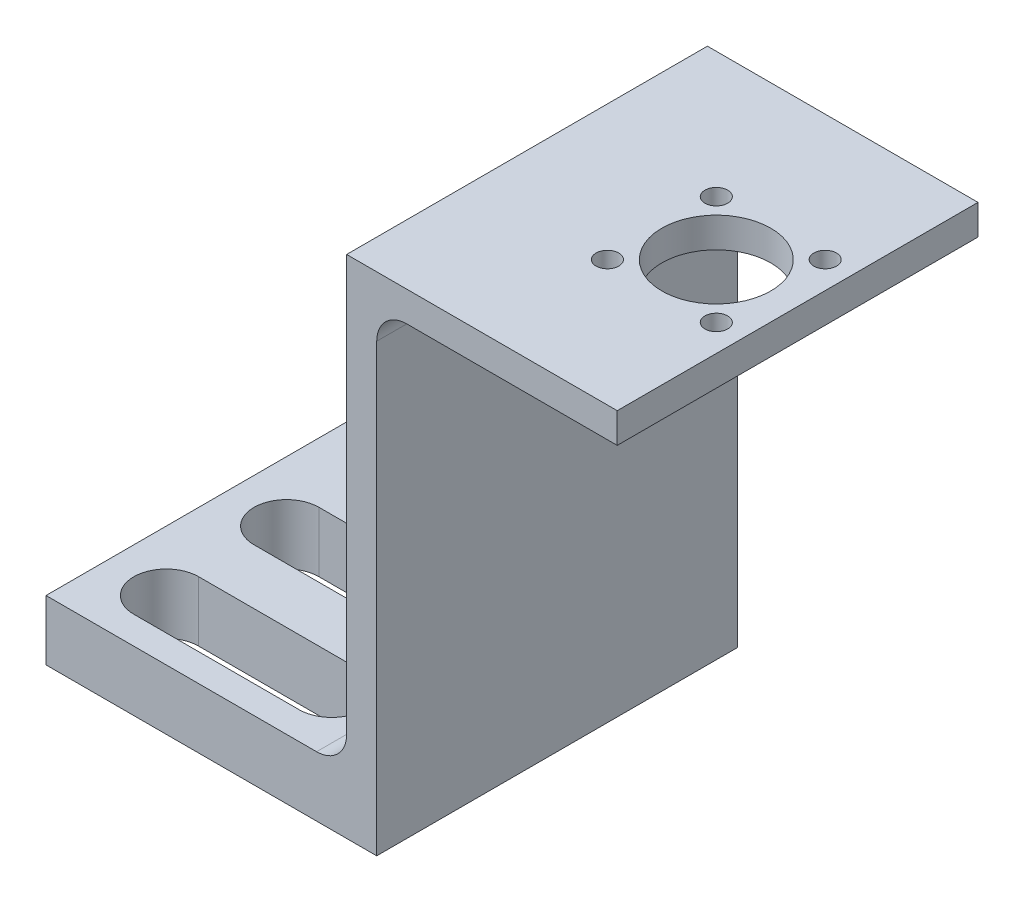
from build123d import *

# Parameters (mm, degrees)
BOSS_EXTRUDE1_DEPTH  = 19.05
FILLET1_R            = 3.175
SKETCH2_R            = 5.75
CUT_EXTRUDE1_DEPTH   = 4.175
M2_CLEARANCE_HOLE1_D = 2.4
CUT_EXTRUDE2_DEPTH   = 7.35
LPATTERN1_COUNT      = 2
LPATTERN1_PITCH      = 12.7
LPATTERN1_COL_COUNT  = 2
LPATTERN1_COL_PITCH  = 12.7


with BuildPart() as part:
    # Sketch1 → Boss-Extrude1 (new body, symmetric)
    with BuildSketch(Plane.XY):
        Polygon((-34.925, 0), (0, 0), (0, 50.2412), (25.4, 50.2412), (25.4, 53.4162), (-3.175, 53.4162), (-3.175, 6.35), (-34.925, 6.35), align=None)
    extrude(amount=BOSS_EXTRUDE1_DEPTH, both=True)

    # Fillet1
    fillet1_edges = [part.edges().sort_by_distance(p)[0] for p in [
        (-3.175, 6.35, 0),
        (0, 50.2412, 0),
    ]]
    fillet(fillet1_edges, radius=FILLET1_R)

    # Sketch2 → Cut-Extrude1 (cut, through all)
    with BuildSketch(Plane(origin=(16.8125, 50.2412, 0), x_dir=(1, 0, 0), z_dir=(0, -1, 0))):
        Circle(SKETCH2_R)
    extrude(amount=-CUT_EXTRUDE1_DEPTH, mode=Mode.SUBTRACT)

    # M2 Clearance Hole1 (through all)
    with Locations(Plane(origin=(16.8125, 50.2412, 0), x_dir=(-1, 0, 0), z_dir=(0, -1, 0))):
        with Locations((-5.75, -5.75), (-5.75, 5.75), (5.75, 5.75), (5.75, -5.75)):
            Hole(M2_CLEARANCE_HOLE1_D / 2)

    # Sketch5 → Cut-Extrude2 (cut, through all)
    with BuildSketch(Plane(origin=(0, 6.35, 0), x_dir=(1, 0, 0), z_dir=(0, 1, 0))):
        with BuildLine():
            Line((-28.575, 3.429), (-11.1125, 3.429))
            ThreePointArc((-11.1125, 3.429), (-7.6835, 0), (-11.1125, -3.429))
            Line((-11.1125, -3.429), (-28.575, -3.429))
            ThreePointArc((-28.575, -3.429), (-32.004, 0), (-28.575, 3.429))
        make_face()
    cut_extrude2 = extrude(amount=-CUT_EXTRUDE2_DEPTH, mode=Mode.SUBTRACT)

    # LPattern1: Cut-Extrude2 ×2
    with Locations(*[(0, 0, i * LPATTERN1_PITCH) for i in range(1, LPATTERN1_COUNT)]):
        add(cut_extrude2, mode=Mode.SUBTRACT)

    # LPattern1 col: Cut-Extrude2 ×2
    with Locations(*[(0, 0, -i * LPATTERN1_COL_PITCH) for i in range(1, LPATTERN1_COL_COUNT)]):
        add(cut_extrude2, mode=Mode.SUBTRACT)


solid = part.part
